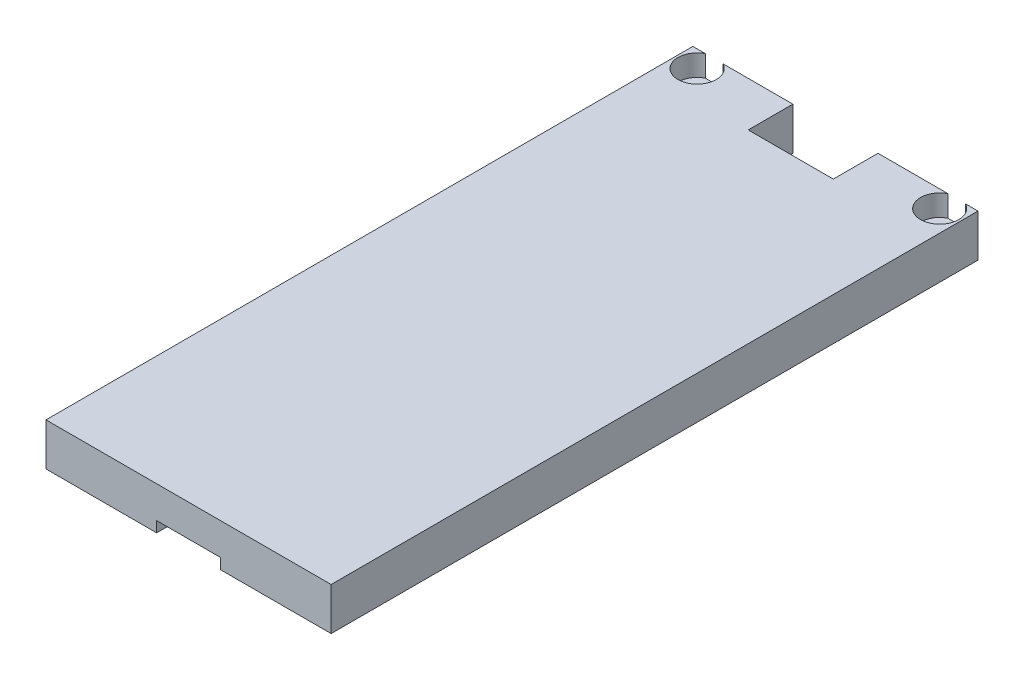
from build123d import *

# Parameters (mm, degrees)
BOSS_EXTRUDE1_DEPTH = 152
SKETCH2_W           = 20
SKETCH2_H           = 10.5
CUT_EXTRUDE1_DEPTH  = 11
CUT_EXTRUDE2_DEPTH  = 5
SKETCH7_R           = 2.6
CUT_EXTRUDE3_DEPTH  = 6


with BuildPart() as part:
    # Sketch1 → Boss-Extrude1 (new body)
    with BuildSketch(Plane.XY):
        Polygon((-33.5, 0), (-33.5, 10), (33.5, 10), (33.5, 0), (7.5, 0), (7.5, 2.5), (-7.5, 2.5), (-7.5, 0), align=None)
    extrude(amount=BOSS_EXTRUDE1_DEPTH)

    # Sketch2 → Cut-Extrude1 (cut, through all)
    with BuildSketch(Plane(origin=(0, 10, 0), x_dir=(1, 0, 0), z_dir=(0, 1, 0))):
        with Locations((0, -5.25)):
            Rectangle(SKETCH2_W, SKETCH2_H)
    extrude(amount=-CUT_EXTRUDE1_DEPTH, mode=Mode.SUBTRACT)

    # Sketch6 → Cut-Extrude2 (cut)
    with BuildSketch(Plane(origin=(0, 10, 0), x_dir=(1, 0, 0), z_dir=(0, 1, 0))):
        with BuildLine():
            Line((-26.44, 0), (-30.56, 0))
            ThreePointArc((-30.56, 0), (-28.5, -8.50079992), (-26.44, 0))
        make_face()
    cut_extrude2 = extrude(amount=-CUT_EXTRUDE2_DEPTH, mode=Mode.SUBTRACT)

    # Sketch7 → Cut-Extrude3 (cut, through all)
    with BuildSketch(Plane(origin=(0, 5, 0), x_dir=(1, 0, 0), z_dir=(0, 1, 0))):
        with Locations((-28.5, -4.00079992)):
            Circle(SKETCH7_R)
    cut_extrude3 = extrude(amount=-CUT_EXTRUDE3_DEPTH, mode=Mode.SUBTRACT)

    # Mirror1: Cut-Extrude2, Cut-Extrude3 across plane
    add(cut_extrude2.mirror(Plane(origin=(0, 0, 0), x_dir=(0, 0, 1), z_dir=(1, 0, 0))), mode=Mode.SUBTRACT)
    add(cut_extrude3.mirror(Plane(origin=(0, 0, 0), x_dir=(0, 0, 1), z_dir=(1, 0, 0))), mode=Mode.SUBTRACT)


solid = part.part
